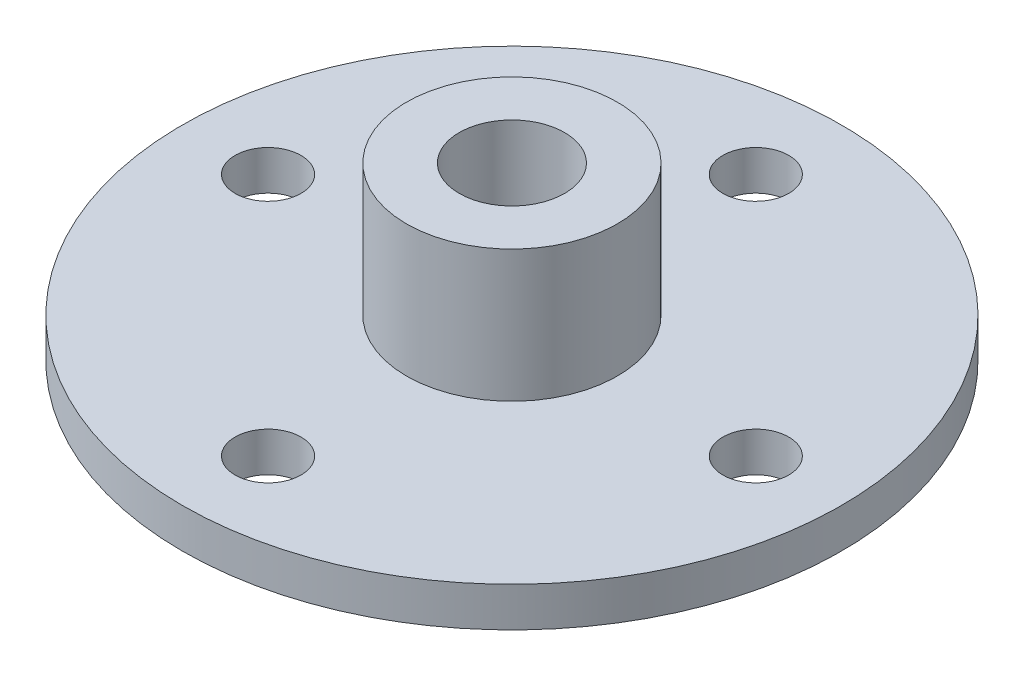
from build123d import *

# Parameters (mm, degrees)
SKETCH2_R           = 25
SKETCH2_R_2         = 2.5
BOSS_EXTRUDE1_DEPTH = 3
SKETCH3_R           = 8
SKETCH3_R_2         = 4
BOSS_EXTRUDE2_DEPTH = 10


with BuildPart() as part:
    # Sketch2 → Boss-Extrude1 (new body)
    with BuildSketch(Plane(origin=(0, 0, 0), x_dir=(1, 0, 0), z_dir=(0, 1, 0))):
        Circle(SKETCH2_R)
        with Locations((-18.5, 0)):
            Circle(SKETCH2_R_2, mode=Mode.SUBTRACT)
        with Locations((0, 18.5)):
            Circle(SKETCH2_R_2, mode=Mode.SUBTRACT)
        with Locations((18.5, 0)):
            Circle(SKETCH2_R_2, mode=Mode.SUBTRACT)
        with Locations((0, -18.5)):
            Circle(SKETCH2_R_2, mode=Mode.SUBTRACT)
    extrude(amount=BOSS_EXTRUDE1_DEPTH)

    # Sketch3 → Boss-Extrude2 (add)
    with BuildSketch(Plane(origin=(0, 3, 0), x_dir=(1, 0, 0), z_dir=(0, 1, 0))):
        Circle(SKETCH3_R)
        Circle(SKETCH3_R_2, mode=Mode.SUBTRACT)
    extrude(amount=BOSS_EXTRUDE2_DEPTH)


solid = part.part
